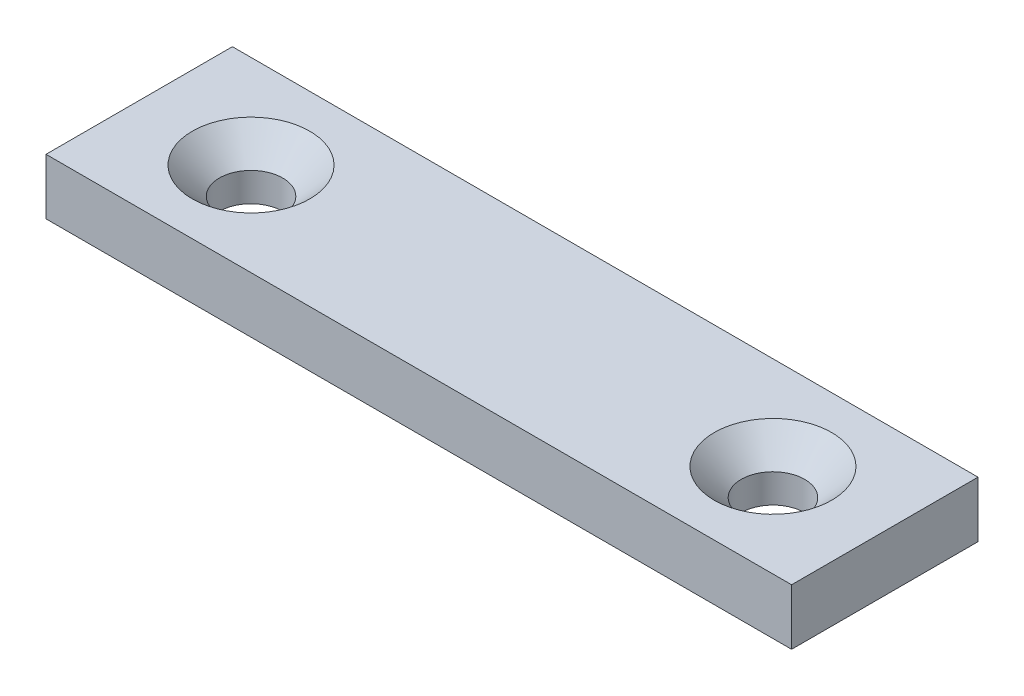
from build123d import *

# Parameters (mm, degrees)
SKETCH1_W                                    = 40
SKETCH1_H                                    = 10
BOSS_EXTRUDE1_DEPTH                          = 3
CSK_FOR_M3_COUNTERSUNK_FLAT_HEAD_SCR_2_COUNT = 2
CSK_FOR_M3_COUNTERSUNK_FLAT_HEAD_SCR_2_PITCH = 28


with BuildPart() as part:
    # Sketch1 → Boss-Extrude1 (new body)
    with BuildSketch(Plane(origin=(0, 0, 0), x_dir=(1, 0, 0), z_dir=(0, 1, 0))):
        Rectangle(SKETCH1_W, SKETCH1_H)
    extrude(amount=BOSS_EXTRUDE1_DEPTH)

    # Sketch3 → CSK for M3 Countersunk Flat Head Screw1 (revolve, cut)
    with BuildSketch(Plane(origin=(-14, 3, 0), x_dir=(0, 0, 1), z_dir=(1, 0, 0))):
        Polygon((0, 0), (0, 3), (1.7, 3), (1.7, 1.45), (3.15, 0), align=None)
    csk_for_m3_countersunk_flat_head_screw1 = revolve(axis=Axis((-14, 9.35, 0), (0, -1, 0)), mode=Mode.SUBTRACT)

    # CSK for M3 Countersunk Flat Head Scr 2: CSK for M3 Countersunk Flat Head Screw1 ×2
    with Locations(*[(i * CSK_FOR_M3_COUNTERSUNK_FLAT_HEAD_SCR_2_PITCH, 0, 0) for i in range(1, CSK_FOR_M3_COUNTERSUNK_FLAT_HEAD_SCR_2_COUNT)]):
        add(csk_for_m3_countersunk_flat_head_screw1, mode=Mode.SUBTRACT)


solid = part.part
